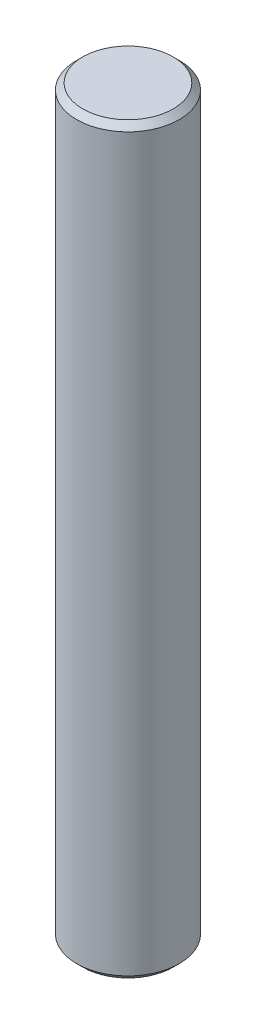
from build123d import *

# Parameters (mm, degrees)
SKETCH1_R           = 2.5
BOSS_EXTRUDE1_DEPTH = 36.2
CHAMFER1_SIZE       = 0.3


with BuildPart() as part:
    # Sketch1 → Boss-Extrude1 (new body)
    with BuildSketch(Plane(origin=(0, 0, 0), x_dir=(1, 0, 0), z_dir=(0, 1, 0))):
        Circle(SKETCH1_R)
    extrude(amount=BOSS_EXTRUDE1_DEPTH)

    # Chamfer1
    chamfer1_edges = [part.edges().sort_by_distance(p)[0] for p in [
        (-2.5, 0, 0),
        (-2.5, 36.2, 0),
    ]]
    chamfer(chamfer1_edges, length=CHAMFER1_SIZE)


solid = part.part
